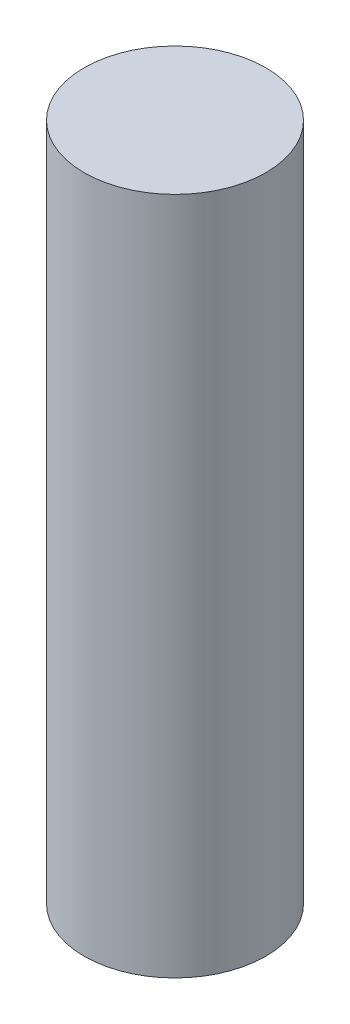
from build123d import *

# Parameters (mm, degrees)
SKETCH1_R           = 3.75
BOSS_EXTRUDE1_DEPTH = 28


with BuildPart() as part:
    # Sketch1 → Boss-Extrude1 (new body)
    with BuildSketch(Plane(origin=(0, 0, 0), x_dir=(1, 0, 0), z_dir=(0, 1, 0))):
        with Locations(Location((0, 0, 0), (0, 0, 270))):  # turned: the seam where the file's is
            Circle(SKETCH1_R)
    extrude(amount=BOSS_EXTRUDE1_DEPTH)


solid = part.part
